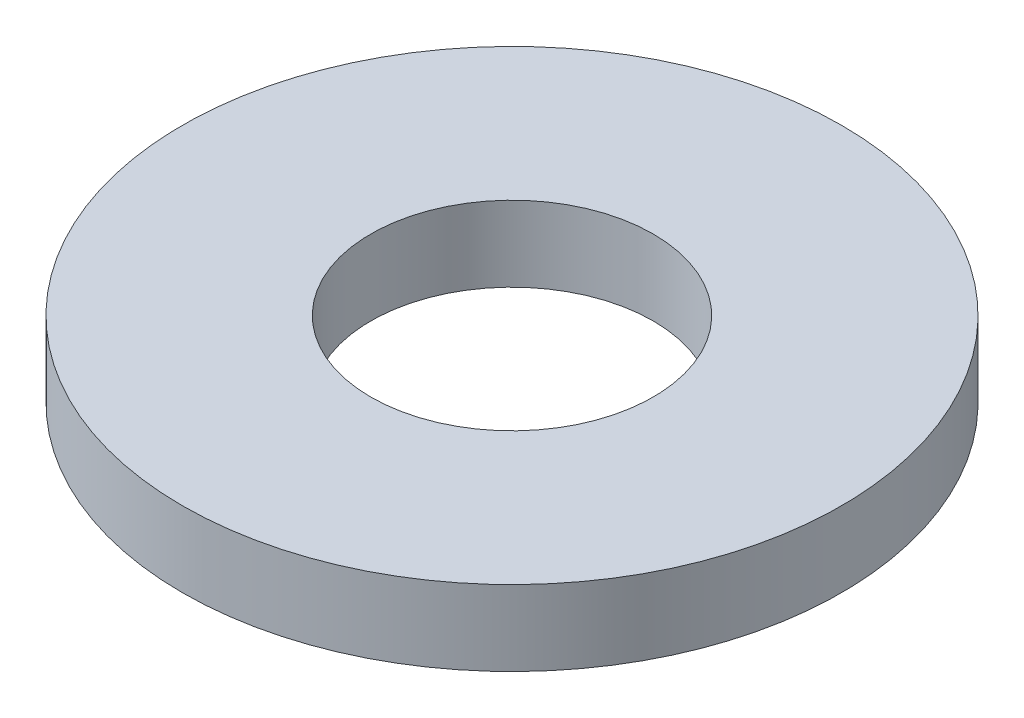
from build123d import *

# Parameters (mm, degrees)
SKETCH_1_R      = 3.5
SKETCH_1_R_2    = 1.5
EXTRUDE_1_DEPTH = 0.8


with BuildPart() as part:
    # 草图1 → 凸台-拉伸1 (new body)
    with BuildSketch(Plane(origin=(0, 0, 0), x_dir=(1, 0, 0), z_dir=(0, 1, 0))):
        Circle(SKETCH_1_R)
        Circle(SKETCH_1_R_2, mode=Mode.SUBTRACT)
    extrude(amount=EXTRUDE_1_DEPTH)


solid = part.part
